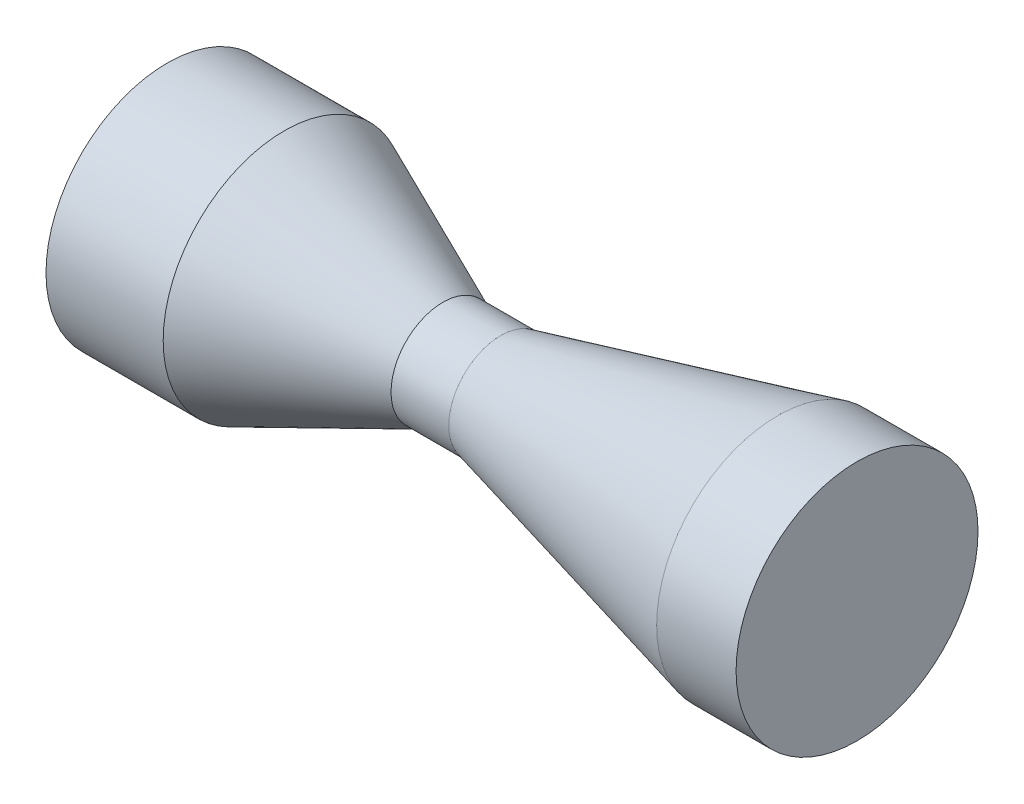
from build123d import *

# Parameters (mm, degrees)
FILLET1_R           = 10
SKETCH2_R           = 35
BOSS_EXTRUDE1_DEPTH = 2
SKETCH3_R           = 34.94624
BOSS_EXTRUDE2_DEPTH = 2


with BuildPart() as part:
    # Sketch1 → Revolve-Thin1 (revolve)
    with BuildSketch(Plane.XY):
        Polygon((-56.494883, 25), (-26.725314, 25), (19.100443, 5), (39.100443, 5), (119.100443, 24.94624), (138.82137, 24.94624), (138.82137, 34.94624), (117.872597, 34.94624), (37.872597, 15), (21.187564, 15), (-24.638193, 35), (-56.494883, 35), align=None)
    revolve(axis=Axis((-43.02316, 0, 0), (1, 0, 0)))

    # Fillet1
    fillet1_edges = [part.edges().sort_by_distance(p)[0] for p in [
        (19.100443, -5, 0),
        (39.100443, -5, 0),
    ]]
    fillet(fillet1_edges, radius=FILLET1_R)

    # Sketch2 → Boss-Extrude1 (add)
    with BuildSketch(Plane.ZY.offset(56.494883)):
        Circle(SKETCH2_R)
    extrude(amount=BOSS_EXTRUDE1_DEPTH)

    # Sketch3 → Boss-Extrude2 (add)
    with BuildSketch(Plane(origin=(138.82137, 0, 0), x_dir=(0, 0, -1), z_dir=(1, 0, 0))):
        Circle(SKETCH3_R)
    extrude(amount=BOSS_EXTRUDE2_DEPTH)


solid = part.part
